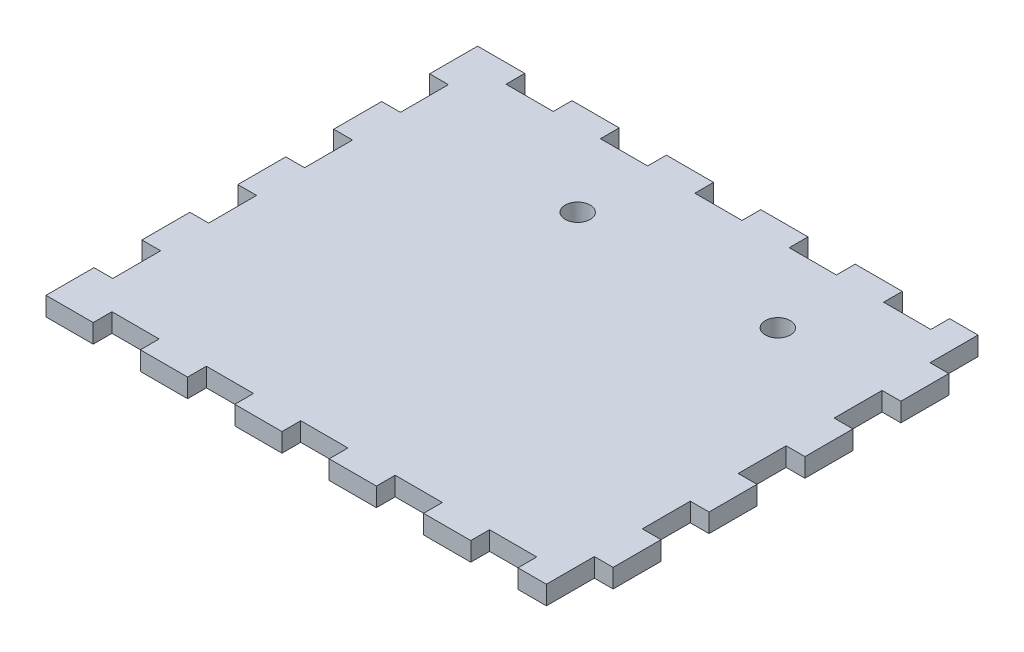
from build123d import *

# Parameters (mm, degrees)
AUFSATZ_LINEAR_AUSTRAGEN1_DEPTH = 3
SKIZZE2_R                       = 2
SCHNITT_LINEAR_AUSTRAGEN1_DEPTH = 3


with BuildPart() as part:
    # Skizze1 → Aufsatz-Linear austragen1 (new body)
    with BuildSketch(Plane(origin=(0, 0, 0), x_dir=(1, 0, 0), z_dir=(0, 1, 0))):
        Polygon((0, 0.000138), (7.544562, 0.000138), (7.544562, 3.000132), (15.090902, 3.000132), (15.090902, 0.000138), (22.635718, 0.000138), (22.635718, 3.000132), (30.18155, 3.000132), (30.18155, 0.000138), (37.726366, 0.000138), (37.726366, 3.000132), (45.272706, 3.000132), (45.272706, 0.000138), (52.81803, 0.000138), (52.81803, 3.000132), (60.36437, 3.000132), (60.36437, 0.000138), (67.90817, 0.000138), (67.90817, 3.000132), (75.45451, 3.000132), (75.45451, 0.000138), (79.99857, 0.000138), (79.99857, 7.666366), (82.99831, 7.666366), (82.99831, 15.332086), (79.99857, 15.332086), (79.99857, 22.99933), (82.99831, 22.99933), (82.99831, 30.665558), (79.99857, 30.665558), (79.99857, 38.333056), (82.99831, 38.333056), (82.99831, 45.99903), (79.99857, 45.99903), (79.99857, 53.666528), (82.99831, 53.666528), (82.99831, 61.332502), (79.99857, 61.332502), (79.99857, 69), (75.45451, 69), (75.45451, 66.000006), (67.90817, 66.000006), (67.90817, 69), (60.36437, 69), (60.36437, 66.000006), (52.81803, 66.000006), (52.81803, 69), (45.272706, 69), (45.272706, 66.000006), (37.726366, 66.000006), (37.726366, 69), (30.18155, 69), (30.18155, 66.000006), (22.635718, 66.000006), (22.635718, 69), (15.090902, 69), (15.090902, 66.000006), (7.544562, 66.000006), (7.544562, 69), (0, 69), (0, 61.332502), (2.99974, 61.332502), (2.99974, 53.666528), (0, 53.666528), (0, 45.99903), (2.99974, 45.99903), (2.99974, 38.333056), (0, 38.333056), (0, 30.665558), (2.99974, 30.665558), (2.99974, 22.99933), (0, 22.99933), (0, 15.332086), (2.99974, 15.332086), (2.99974, 7.666366), (0, 7.666366), align=None)
    extrude(amount=AUFSATZ_LINEAR_AUSTRAGEN1_DEPTH)

    # Skizze2 → Schnitt-Linear austragen1 (cut)
    with BuildSketch(Plane.XZ):
        with Locations((62.99857, -54.000006)):
            Circle(SKIZZE2_R)
        with Locations((30.99857, -54.000006)):
            Circle(SKIZZE2_R)
    extrude(amount=-SCHNITT_LINEAR_AUSTRAGEN1_DEPTH, mode=Mode.SUBTRACT)


solid = part.part
